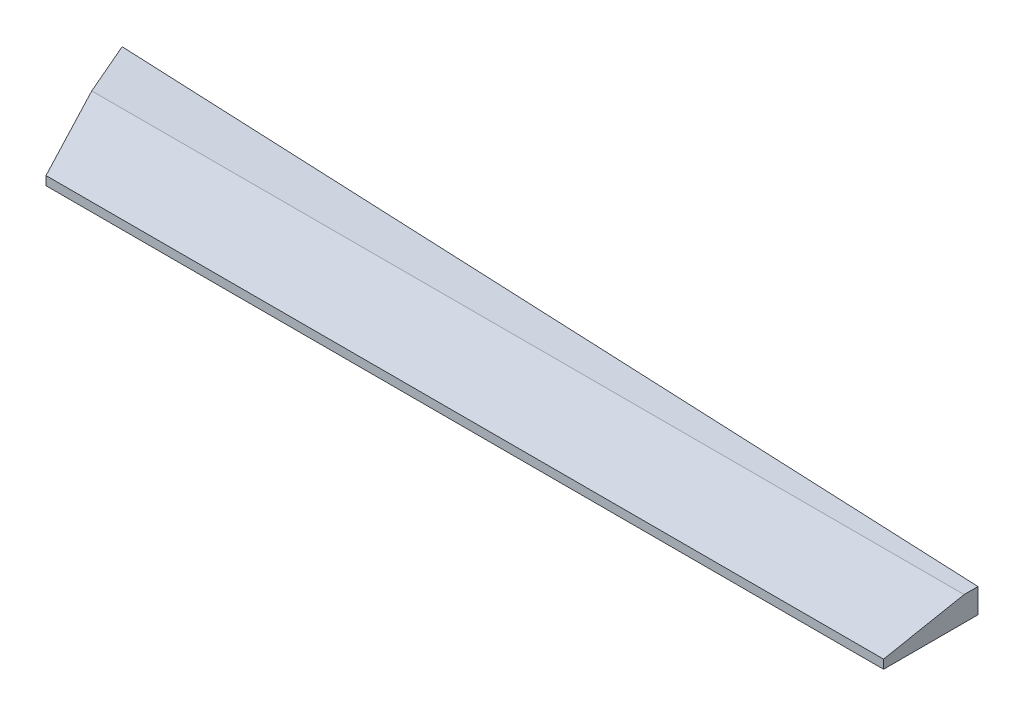
from build123d import *

# Parameters (mm, degrees)
BOSS_EXTRUDE1_DEPTH = 3.81
CHAMFER1_SIZE       = 12.54
CHAMFER1_SIZE2      = 2.437529077


with BuildPart() as part:
    # Sketch2 → Boss-Extrude1 (new body)
    with BuildSketch(Plane(origin=(0, 0, 0), x_dir=(1, 0, 0), z_dir=(0, 1, 0))):
        Polygon((98.033263401, -1041.106556332), (107.044429893, -1061.974520841), (237.469208074, -1061.974520841), (237.469208074, -1047.272091301), align=None)
    extrude(amount=BOSS_EXTRUDE1_DEPTH)

    # Chamfer1
    chamfer1_edges = [part.edges().sort_by_distance(p)[0] for p in [
        (172.256818983, 3.81, 1061.974520841),
    ]]
    chamfer1_side = [part.faces().sort_by_distance(p)[0] for p in [
        (166.193416202, 3.81, 1052.913037199),
    ]]
    chamfer(chamfer1_edges, length=CHAMFER1_SIZE, length2=CHAMFER1_SIZE2, reference=chamfer1_side[0])


solid = part.part
